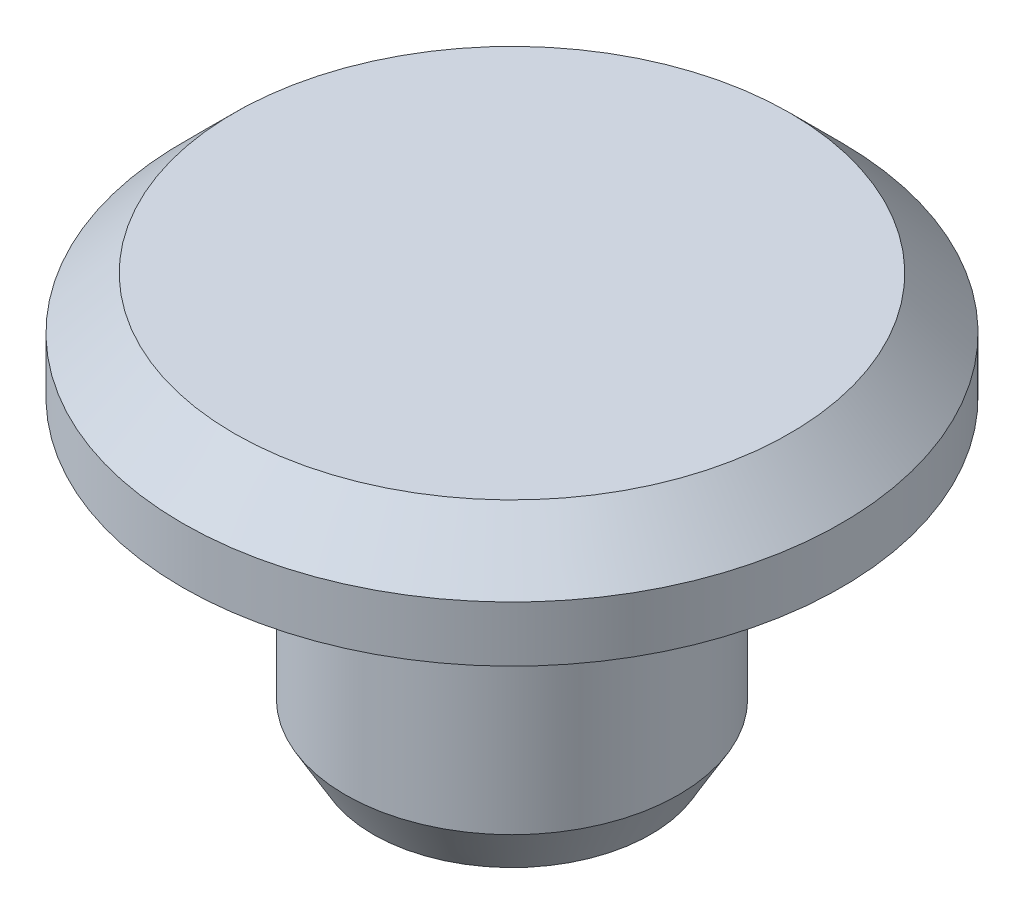
from build123d import *

# Parameters (mm, degrees)
CUT_EXTRUDE1_DEPTH = 5.5
CHAMFER1_SIZE      = 0.5
CHAMFER1_SIZE2     = 0.866025404


with BuildPart() as part:
    # Sketch1 → Revolve1 (revolve)
    with BuildSketch(Plane.XY):
        Polygon((0, 0), (0, 7.5), (-5, 7.5), (-5.932615316, 6.567384684), (-5.932615316, 5.567384684), (-3, 4.5), (-3, 0), align=None)
    revolve(axis=Axis((0, 14, 0), (0, -1, 0)))

    # Sketch2 → Cut-Extrude1 (cut)
    with BuildSketch(Plane.XZ):
        with BuildLine():
            Line((1.75, -1.414213562), (1.75, 1.414213562))
            ThreePointArc((1.75, 1.414213562), (0, 2.25), (-1.75, 1.414213562))
            Line((-1.75, 1.414213562), (-1.75, -1.414213562))
            ThreePointArc((-1.75, -1.414213562), (0, -2.25), (1.75, -1.414213562))
        make_face()
    extrude(amount=-CUT_EXTRUDE1_DEPTH, mode=Mode.SUBTRACT)

    # Chamfer1
    chamfer1_edges = [part.edges().sort_by_distance(p)[0] for p in [
        (3, 0, 0),
    ]]
    chamfer1_side = [part.faces().sort_by_distance(p)[0] for p in [
        (2.915147186, 0, 0),
    ]]
    chamfer(chamfer1_edges, length=CHAMFER1_SIZE, length2=CHAMFER1_SIZE2, reference=chamfer1_side[0])


solid = part.part
